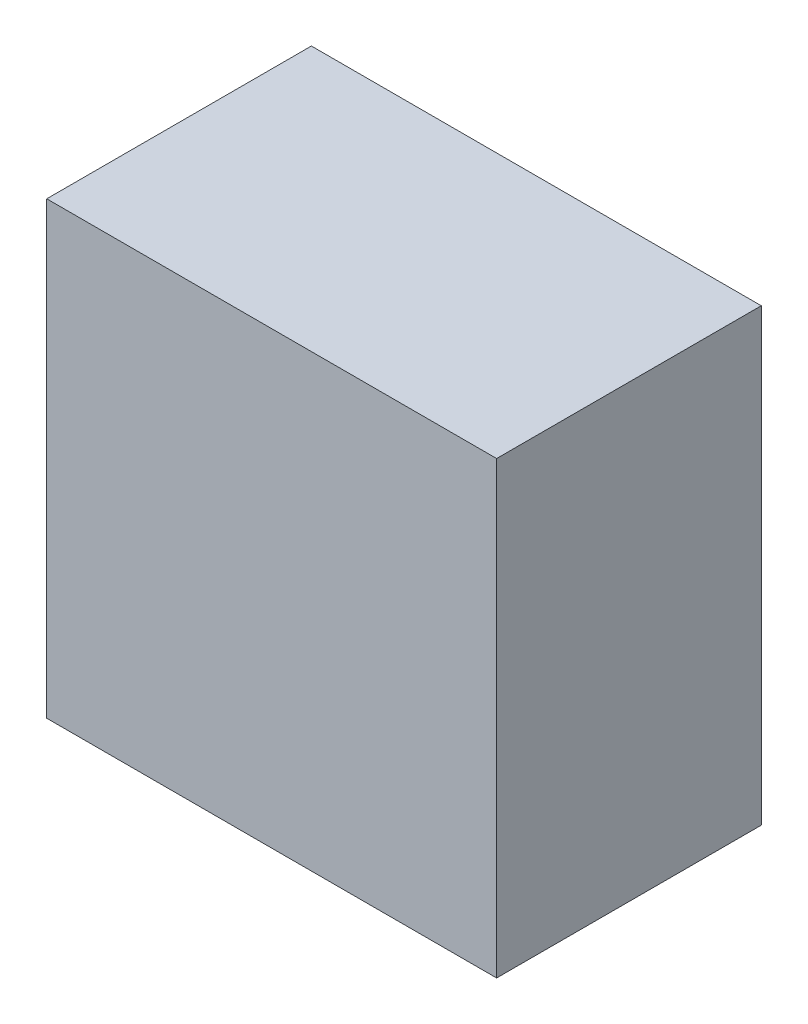
from build123d import *

# Parameters (mm, degrees)
SKETCH1_W           = 17
SKETCH1_H           = 17
BOSS_EXTRUDE1_DEPTH = 10


with BuildPart() as part:
    # Sketch1 → Boss-Extrude1 (new body)
    with BuildSketch(Plane.XY):
        with Locations((-1.327586207, 6.431034483)):
            Rectangle(SKETCH1_W, SKETCH1_H)
    extrude(amount=BOSS_EXTRUDE1_DEPTH)


solid = part.part
